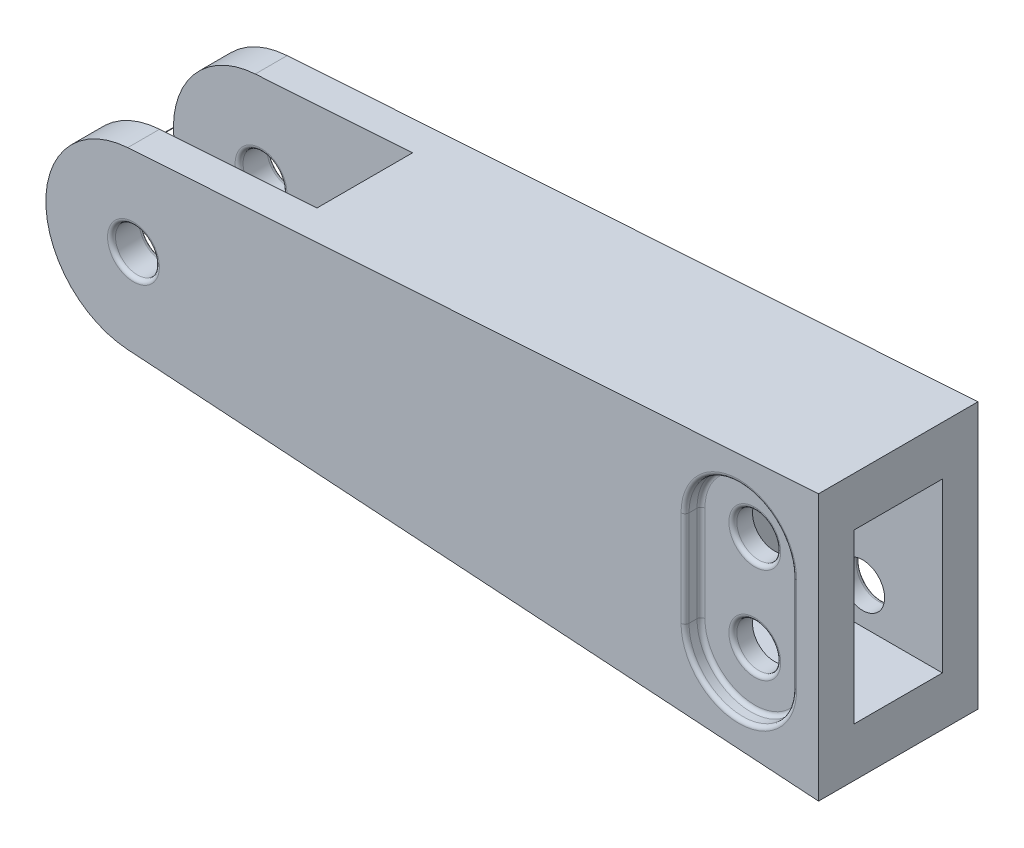
from build123d import *

# Parameters (mm, degrees)
BOSS_EXTRUDE1_DEPTH     = 20
SKETCH2_W               = 11.07
SKETCH2_H               = 21.07
CUT_EXTRUDE1_DEPTH      = 20
SKETCH4_W               = 30
SKETCH4_H               = 12
CUT_EXTRUDE2_DEPTH      = 17.695671227
CUT_EXTRUDE2_DEPTH_BACK = 17.695671227
SKETCH5_R               = 2.75
CUT_EXTRUDE3_DEPTH      = 21
SKETCH6_R               = 2.75
CUT_EXTRUDE4_DEPTH      = 21
CUT_EXTRUDE5_DEPTH      = 2
FILLET2_R               = 0.5


with BuildPart() as part:
    # Sketch1 → Boss-Extrude1 (new body)
    with BuildSketch(Plane.XY):
        with BuildLine():
            Line((-147.582315954, 10.968690843), (-60.923560458, 16.695671227))
            Line((-60.923560458, 16.695671227), (-60.923560458, -16.695671227))
            Line((-60.923560458, -16.695671227), (-147.582315954, -10.968690843))
            ThreePointArc((-147.582315954, -10.968690843), (-157.850050011, 0), (-147.582315954, 10.968690843))
        make_face()
    extrude(amount=BOSS_EXTRUDE1_DEPTH)

    # Sketch2 → Cut-Extrude1 (cut)
    with BuildSketch(Plane(origin=(-60.923560458, 0, 0), x_dir=(0, 0, -1), z_dir=(1, 0, 0))):
        with Locations((-10, 0)):
            Rectangle(SKETCH2_W, SKETCH2_H)
    extrude(amount=-CUT_EXTRUDE1_DEPTH, mode=Mode.SUBTRACT)

    # Sketch4 → Cut-Extrude2 (cut, two sides)
    with BuildSketch(Plane(origin=(0, 0, 0), x_dir=(1, 0, 0), z_dir=(0, 1, 0))) as cut_extrude2_sk:
        with Locations((-142.849999312, -10)):
            Rectangle(SKETCH4_W, SKETCH4_H)
    extrude(amount=CUT_EXTRUDE2_DEPTH, mode=Mode.SUBTRACT)
    extrude(cut_extrude2_sk.sketch, amount=-CUT_EXTRUDE2_DEPTH_BACK, mode=Mode.SUBTRACT)

    # Sketch5 → Cut-Extrude3 (cut, through all)
    with BuildSketch(Plane(origin=(0, 0, 0), x_dir=(-1, 0, 0), z_dir=(0, 0, -1))):
        with Locations((146.857432739, 0)):
            Circle(SKETCH5_R)
    extrude(amount=-CUT_EXTRUDE3_DEPTH, mode=Mode.SUBTRACT)

    # Sketch6 → Cut-Extrude4 (cut, through all)
    with BuildSketch(Plane(origin=(0, 0, 0), x_dir=(-1, 0, 0), z_dir=(0, 0, -1))):
        with Locations((70.923560458, -6)):
            Circle(SKETCH6_R)
        with Locations((70.923560458, 6)):
            Circle(SKETCH6_R)
    extrude(amount=-CUT_EXTRUDE4_DEPTH, mode=Mode.SUBTRACT)

    # Sketch8 → Cut-Extrude5 (cut)
    with BuildSketch(Plane(origin=(0, 0, 0), x_dir=(-1, 0, 0), z_dir=(0, 0, -1))):
        with BuildLine():
            Line((64.173560458, 6), (64.173560458, -6))
            ThreePointArc((64.173560458, -6), (70.923560458, -12.75), (77.673560458, -6))
            Line((77.673560458, -6), (77.673560458, 6))
            ThreePointArc((77.673560458, 6), (70.923560458, 12.75), (64.173560458, 6))
        make_face()
    cut_extrude5 = extrude(amount=-CUT_EXTRUDE5_DEPTH, mode=Mode.SUBTRACT)

    # Mirror1: Cut-Extrude5 across plane
    add(cut_extrude5.mirror(Plane(origin=(0, 0, 10), x_dir=(1, 0, 0), z_dir=(0, 0, -1))), mode=Mode.SUBTRACT)

    # Fillet2
    fillet2_edges = [part.edges().sort_by_distance(p)[0] for p in [
        (-70.923560458, 12.75, 18),
        (-64.173560458, 0, 18),
        (-70.923560458, -12.75, 18),
        (-77.673560458, 0, 18),
        (-68.173560458, 6, 18),
        (-70.923560458, 12.75, 20),
        (-64.173560458, 0, 20),
        (-70.923560458, -12.75, 20),
        (-77.673560458, 0, 20),
        (-68.173560458, -6, 18),
        (-144.107432739, 0, 4),
        (-144.107432739, 0, 20),
        (-144.107432739, 0, 16),
        (-144.107432739, 0, 0),
        (-68.173560458, 6, 2),
        (-70.923560458, 12.75, 0),
        (-64.173560458, 0, 0),
        (-70.923560458, -12.75, 0),
        (-77.673560458, 0, 0),
        (-70.923560458, 12.75, 2),
        (-77.673560458, 0, 2),
        (-70.923560458, -12.75, 2),
        (-64.173560458, 0, 2),
        (-68.173560458, -6, 2),
    ]]
    fillet(fillet2_edges, radius=FILLET2_R)


solid = part.part
